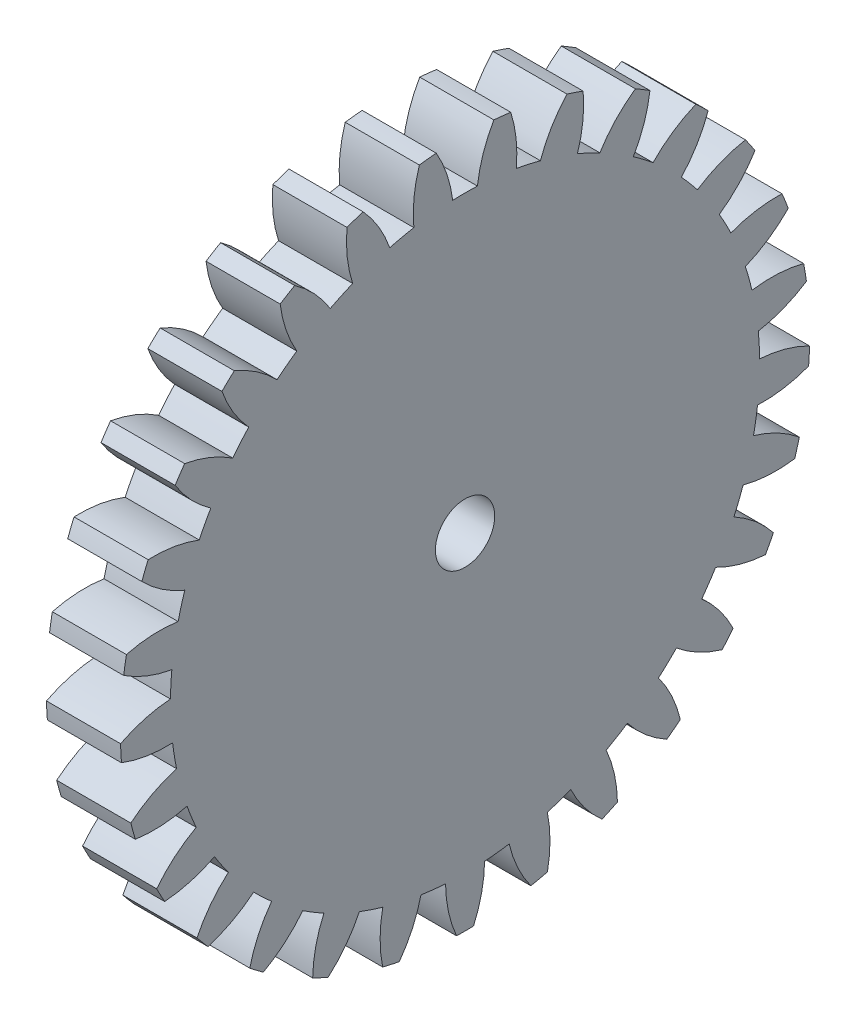
from build123d import *

# Parameters (mm, degrees)
BASPROSKE_W     = 5
BASPROSKE_H     = 23.25
TOOTHCUT_DEPTH  = 34.258457571
TEETHCUTS_COUNT = 29
TEETHCUTS_ANGLE = 347.586206897
BORSKE_R        = 2
BORE_DEPTH      = 50.0000508


with BuildPart() as part:
    # BasProSke → Base-Revolve (revolve)
    with BuildSketch(Plane(origin=(0, 0, 0), x_dir=(1, 0, 0), z_dir=(0, 1, 0)), mode=Mode.PRIVATE) as base_revolve_sk:
        with Locations((2.5, 11.625)):
            Rectangle(BASPROSKE_W, BASPROSKE_H)
    revolve(base_revolve_sk.sketch.rotate(Axis((-10, 0, 0), (1, 0, 0)), 180), axis=Axis((-10, 0, 0), (1, 0, 0)))

    # TooCutSke → ToothCut (cut, through all)
    with BuildSketch(Plane(origin=(0, 0, 0), x_dir=(0, 0, -1), z_dir=(1, 0, 0))):
        with BuildLine():
            ThreePointArc((0.834195613, 19.856484928), (0, 19.874), (-0.834195613, 19.856484928))
            ThreePointArc((-0.834195613, 19.856484928), (-1.225085734, 21.582118152), (-1.957021413, 23.192979807))
            ThreePointArc((-1.957021413, 23.192979807), (0, 23.2754), (1.957021413, 23.192979807))
            ThreePointArc((1.957021413, 23.192979807), (1.225085734, 21.582118152), (0.834195613, 19.856484928))
        make_face()
    toothcut = extrude(amount=TOOTHCUT_DEPTH, mode=Mode.SUBTRACT)

    # TeethCuts: ToothCut ×29 about axis
    teethcuts_axis = Axis((-10, 0, 0), (1, 0, 0))
    for i in range(1, TEETHCUTS_COUNT):
        add(toothcut.rotate(teethcuts_axis, i * TEETHCUTS_ANGLE / (TEETHCUTS_COUNT - 1)), mode=Mode.SUBTRACT)

    # BorSke → Bore (cut, symmetric)
    with BuildSketch(Plane(origin=(0, 0, 0), x_dir=(0, 0, -1), z_dir=(1, 0, 0))):
        with Locations(Location((0, 0, 0), (0, 0, 180))):
            Circle(BORSKE_R)
    extrude(amount=BORE_DEPTH, both=True, mode=Mode.SUBTRACT)


solid = part.part
